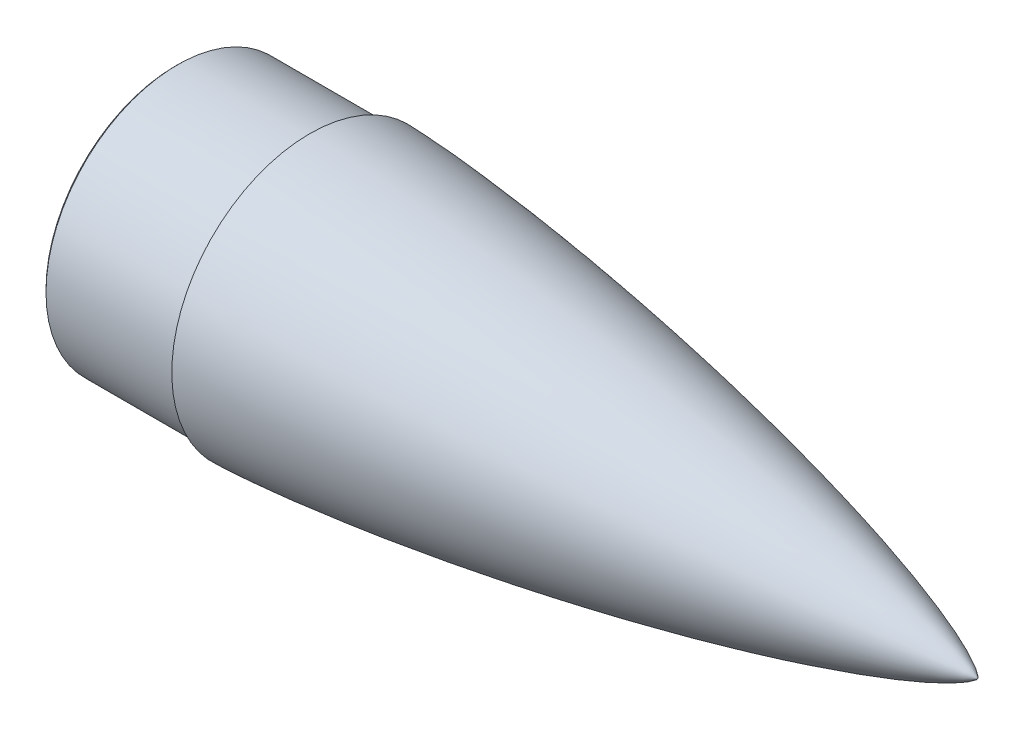
from build123d import *

# Parameters (mm, degrees)
CHAMFER1_SIZE = 1.5


with BuildPart() as part:
    # Sketch10 → Revolve1 (revolve)
    with BuildSketch(Plane.XY):
        with BuildLine():
            Line((10.635874649, 77.55), (-82.154687473, 77.55))
            Line((-82.154687473, 77.55), (-82.154687473, 80.55))
            Line((-82.154687473, 80.55), (0.395312527, 80.55))
            Line((0.395312527, 80.55), (0.395312527, 84.55))
            add(Edge.make_bspline(
                [(409.481241764, 0), (409.478822602, 0.013487485), (409.471791677, 0.039860166), (409.44996872, 0.090299923), (409.405170369, 0.17360441), (409.338622841, 0.274707126), (409.233198984, 0.41435486), (409.071473276, 0.602630626), (408.814393211, 0.868443814), (408.376034855, 1.268699656), (407.623681971, 1.874044786), (406.300886659, 2.80689474), (403.950805973, 4.254089379), (399.800317204, 6.473924098), (392.936954952, 9.659940464), (381.088920065, 14.458133958), (364.027881021, 20.439719136), (342.565783158, 27.076024485), (317.737377085, 33.948483164), (292.149117176, 40.40246553), (266.444005618, 46.372709865), (240.645313143, 51.922660722), (214.767260005, 57.089687778), (188.820024567, 61.896435261), (166.061529058, 65.795828503), (146.518269237, 68.91929539), (130.209185955, 71.372758968), (117.148436808, 73.24373966), (104.074432981, 75.019811614), (92.623234339, 76.487170689), (82.799789073, 77.679439415), (74.608164803, 78.626986039), (68.051597153, 79.356294804), (61.491752048, 80.05557077), (54.928607929, 80.723256072), (48.362151485, 81.357482811), (41.792344871, 81.955972251), (36.040789439, 82.445886318), (31.108722933, 82.839416847), (26.997195352, 83.148219974), (23.707077769, 83.383057729), (20.091694532, 83.626627241), (16.724439325, 83.837024008), (13.60553361, 84.016286235), (10.735186496, 84.166698043), (8.43841491, 84.277064727), (6.141138628, 84.376754941), (4.13054718, 84.451863988), (2.40683331, 84.506841756), (1.257457843, 84.534358411), (0.682722204, 84.546806796), (0.395312527, 84.55)],
                knots=[0, 0, 0, 0, 0, 0.000130123, 0.000260245, 0.000520491, 0.000900391, 0.00128029, 0.001925099, 0.002881508, 0.004418208, 0.006927086, 0.011110697, 0.018279138, 0.03067276, 0.051704469, 0.08310228, 0.139908797, 0.202702513, 0.265496165, 0.328289682, 0.391083359, 0.453876973, 0.516670577, 0.579464197, 0.642257765, 0.673654596, 0.705051427, 0.736448267, 0.767845106, 0.799241874, 0.814940257, 0.830638641, 0.846337073, 0.862035505, 0.877733936, 0.893432368, 0.90913072, 0.924829072, 0.932678248, 0.940527424, 0.9483766, 0.956225776, 0.967169332, 0.97264111, 0.978112888, 0.983584666, 0.989056444, 0.994528222, 0.997264111, 1, 1, 1, 1, 1], degree=4))
            Line((409.481241764, 0), (369.481241764, 0))
            add(Edge.make_bspline(
                [(369.481241764, 0), (369.479136427, 0.012313297), (369.472953977, 0.036418276), (369.45359797, 0.082627122), (369.414328459, 0.157917729), (369.356429793, 0.248740065), (369.265020656, 0.373899739), (369.123861296, 0.543957157), (368.897069053, 0.786384211), (368.508258256, 1.152912242), (367.837373575, 1.709573455), (366.657962177, 2.566700168), (364.558017618, 3.899200908), (360.865618953, 5.934211086), (354.805328477, 8.836759468), (344.391180354, 13.197167349), (329.431545128, 18.632620483), (310.628295275, 24.669689899), (288.864918388, 30.935059762), (266.427265346, 36.829336196), (243.880560946, 42.290562892), (221.246296693, 47.375026348), (198.537651833, 52.115899956), (175.763975962, 56.533212855), (155.78553292, 60.122875559), (138.627190745, 63.002853292), (124.306793182, 65.268344632), (112.837717735, 66.998082779), (101.356055229, 68.642323644), (91.298712805, 70.002886444), (82.670377365, 71.110042236), (75.47491226, 71.991156585), (69.715412986, 72.670115403), (63.95277294, 73.321953145), (58.186965818, 73.945246758), (52.417974559, 74.538293621), (46.645754847, 75.099004997), (41.592187646, 75.559059761), (37.258461535, 75.929453889), (33.645590132, 76.220759301), (30.754418422, 76.442688114), (27.600376545, 76.671760648), (24.183147106, 76.902673679), (20.995230634, 77.098317274), (18.036853679, 77.259743837), (15.57072725, 77.378462484), (13.843977698, 77.451161401), (12.363561894, 77.505178568), (11.376380067, 77.533293738), (10.882741728, 77.546187792), (10.635874649, 77.55)],
                knots=[0, 0, 0, 0, 0, 0.000134949, 0.000269899, 0.000539798, 0.000919537, 0.001299277, 0.001947431, 0.00293136, 0.004511869, 0.007081312, 0.011380263, 0.018707867, 0.031423867, 0.052705479, 0.084103008, 0.140910136, 0.203703492, 0.266497064, 0.329290816, 0.392084375, 0.454877964, 0.517671564, 0.580465191, 0.643258828, 0.674655593, 0.706052358, 0.737449114, 0.768845869, 0.800242661, 0.815941057, 0.831639453, 0.847337924, 0.863036395, 0.878734865, 0.894433336, 0.910131716, 0.925830096, 0.933679285, 0.941528475, 0.949377665, 0.957226855, 0.967920141, 0.978613427, 0.983960071, 0.989306714, 0.994653357, 0.997326678, 1, 1, 1, 1, 1], degree=4))
        make_face()
    revolve(axis=Axis((446.938975823, 0, 0), (-1, 0, 0)))

    # Chamfer1
    chamfer1_edges = [part.edges().sort_by_distance(p)[0] for p in [
        (-82.154687473, -80.55, 0),
    ]]
    chamfer(chamfer1_edges, length=CHAMFER1_SIZE)


solid = part.part
